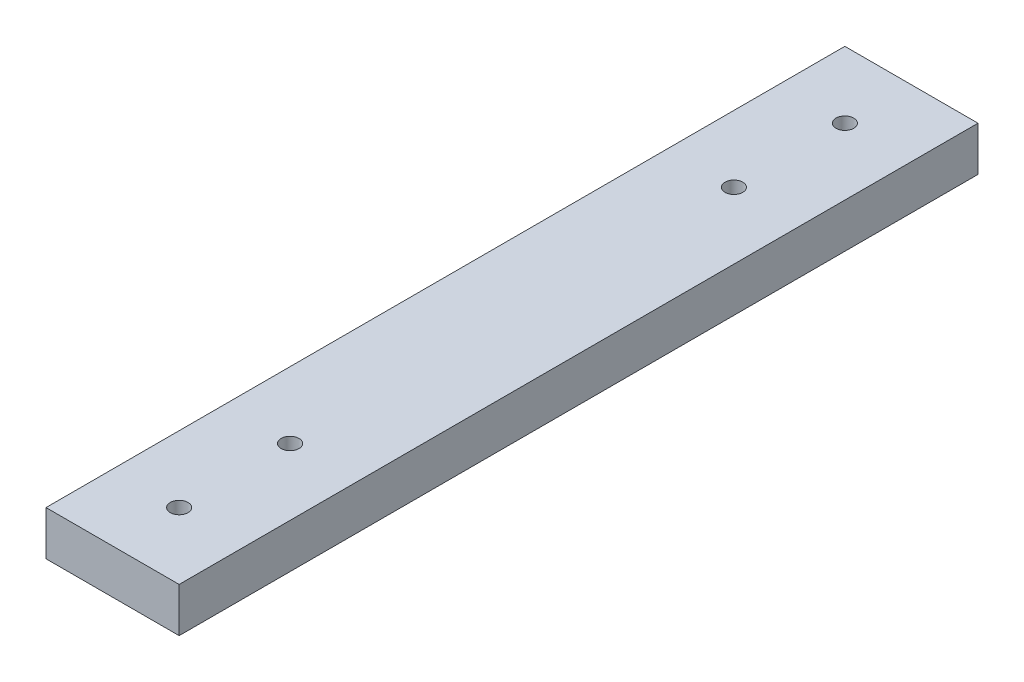
from build123d import *

# Parameters (mm, degrees)
SKETCH1_W           = 30
SKETCH1_H           = 180
SKETCH1_R           = 2
BOSS_EXTRUDE1_DEPTH = 10


with BuildPart() as part:
    # Sketch1 → Boss-Extrude1 (new body)
    with BuildSketch(Plane(origin=(0, 0, 0), x_dir=(1, 0, 0), z_dir=(0, 1, 0))):
        with Locations((15, 90)):
            Rectangle(SKETCH1_W, SKETCH1_H)
        with Locations((15, 15)):
            Circle(SKETCH1_R, mode=Mode.SUBTRACT)
        with Locations((15, 140)):
            Circle(SKETCH1_R, mode=Mode.SUBTRACT)
        with Locations((15, 40)):
            Circle(SKETCH1_R, mode=Mode.SUBTRACT)
        with Locations((15, 165)):
            Circle(SKETCH1_R, mode=Mode.SUBTRACT)
    extrude(amount=BOSS_EXTRUDE1_DEPTH)


solid = part.part
